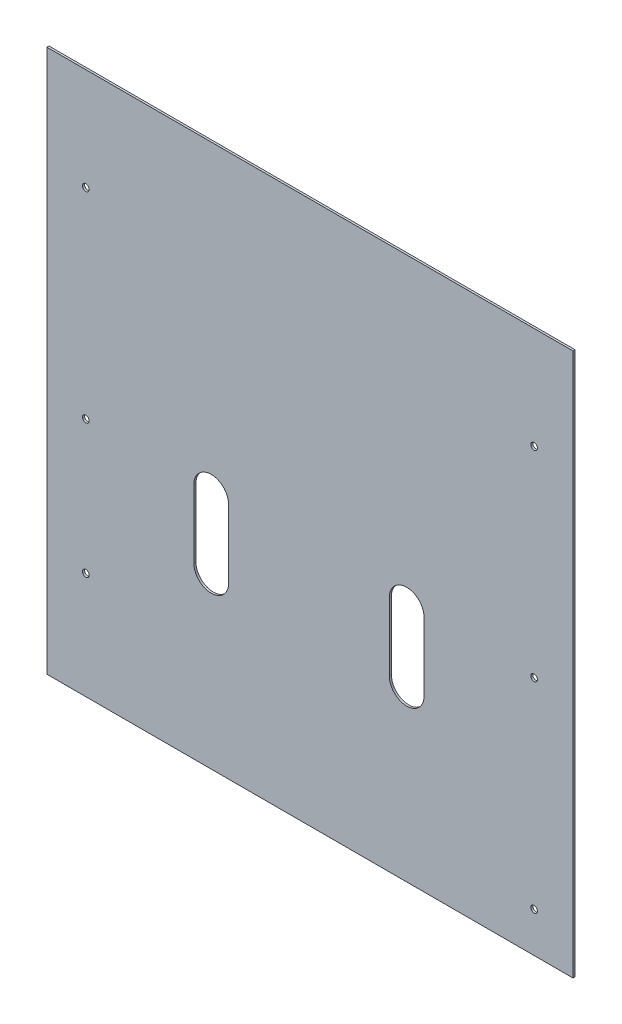
from build123d import *

# Parameters (mm, degrees)
SKETCH1_W                             = 196.85
SKETCH1_H                             = 203.2
BOSS_EXTRUDE1_DEPTH                   = 0.7747
CUT_EXTRUDE7_DEPTH                    = 1.7747
SKETCH4_W                             = 196.85
SKETCH4_H                             = 0.6096
BOSS_EXTRUDE2_DEPTH                   = 12
SKETCH14_W                            = 196.85
SKETCH14_H                            = 11.938
BOSS_EXTRUDE3_DEPTH                   = 0.7747
SKETCH13_W                            = 196.85
SKETCH13_H                            = 0.6096
CUT_EXTRUDE9_DEPTH                    = 12
CSK_FOR_M3_FLAT_HEAD_MACHINE_SCREW3_D = 2.5
SKETCH19_W                            = 182.676330849
SKETCH19_H                            = 33.741187375
BOSS_EXTRUDE4_DEPTH                   = 0.7747
SKETCH21_W                            = 22.718000829
SKETCH21_H                            = 22.312299049
SKETCH21_W_2                          = 21.538835619
SKETCH21_H_2                          = 16.643270878
BOSS_EXTRUDE5_DEPTH                   = 0.7747
SKETCH22_W                            = 13.90531837
SKETCH22_H                            = 14.215216999
SKETCH22_W_2                          = 12.509578485
SKETCH22_H_2                          = 9.075576548
BOSS_EXTRUDE6_DEPTH                   = 0.7747


with BuildPart() as part:
    # Sketch1 → Boss-Extrude1 (new body)
    with BuildSketch(Plane(origin=(0, 0, 0), x_dir=(1, 0, 0), z_dir=(0, 0, -1))):
        with Locations((-104.775, 135.4)):
            Rectangle(SKETCH1_W, SKETCH1_H)
    extrude(amount=BOSS_EXTRUDE1_DEPTH)

    # Sketch2 → Cut-Extrude7 (cut, through all)
    with BuildSketch(Plane(origin=(0, 0, -0.7747), x_dir=(1, 0, 0), z_dir=(0, 0, -1))):
        with BuildLine():
            Line((-135.221253236, 173.5), (-135.221253236, 148))
            ThreePointArc((-135.221253236, 148), (-141.721253236, 141.5), (-148.221253236, 148))
            Line((-148.221253236, 148), (-148.221253236, 173.5))
            ThreePointArc((-148.221253236, 173.5), (-141.721253236, 180), (-135.221253236, 173.5))
        make_face()
        with BuildLine():
            Line((-62.069253236, 173.5), (-62.069253236, 148))
            ThreePointArc((-62.069253236, 148), (-68.569253236, 141.5), (-75.069253236, 148))
            Line((-75.069253236, 148), (-75.069253236, 173.5))
            ThreePointArc((-75.069253236, 173.5), (-68.569253236, 180), (-62.069253236, 173.5))
        make_face()
    extrude(amount=-CUT_EXTRUDE7_DEPTH, mode=Mode.SUBTRACT)

    # Sketch4 → Boss-Extrude2 (add)
    with BuildSketch(Plane.XY):
        with Locations((-104.775, -34.1048)):
            Rectangle(SKETCH4_W, SKETCH4_H)
    extrude(amount=BOSS_EXTRUDE2_DEPTH)

    # Sketch14 → Boss-Extrude3 (add)
    with BuildSketch(Plane.XY):
        with Locations((-104.775, -53.935004147)):
            Rectangle(SKETCH14_W, SKETCH14_H)
    extrude(amount=-BOSS_EXTRUDE3_DEPTH)

    # Sketch13 → Cut-Extrude9 (cut)
    with BuildSketch(Plane.XY.offset(12)):
        with Locations((-104.775, -34.1048)):
            Rectangle(SKETCH13_W, SKETCH13_H)
    extrude(amount=-CUT_EXTRUDE9_DEPTH, mode=Mode.SUBTRACT)

    # CSK for M3 Flat Head Machine Screw3 (through all)
    with Locations(Plane.XY):
        with Locations((-188.645, -72), (-188.645, -222), (-188.645, -197), (-188.645, -172), (-188.645, -147), (-188.645, -122), (-188.645, -97)):
            csk_for_m3_flat_head_machine_screw3 = Hole(CSK_FOR_M3_FLAT_HEAD_MACHINE_SCREW3_D / 2)

    # Mirror1: CSK for M3 Flat Head Machine Screw3 across plane
    add(csk_for_m3_flat_head_machine_screw3.mirror(Plane(origin=(-104.775, 0, 0), x_dir=(0, 0, 1), z_dir=(1, 0, 0))), mode=Mode.SUBTRACT)

    # Sketch19 → Boss-Extrude4 (add)
    with BuildSketch(Plane(origin=(0, 0, -0.7747), x_dir=(-1, 0, 0), z_dir=(0, 0, -1))):
        with Locations((101.266706015, -109.837466763)):
            Rectangle(SKETCH19_W, SKETCH19_H)
    extrude(amount=-BOSS_EXTRUDE4_DEPTH)

    # Sketch21 → Boss-Extrude5 (add)
    with BuildSketch(Plane(origin=(0, 0, -0.7747), x_dir=(-1, 0, 0), z_dir=(0, 0, -1))):
        with Locations((185.571692861, -170.919383368)):
            Rectangle(SKETCH21_W, SKETCH21_H)
        with Locations((24.271371833, -173.753897453)):
            Rectangle(SKETCH21_W_2, SKETCH21_H_2)
    extrude(amount=-BOSS_EXTRUDE5_DEPTH)

    # Sketch22 → Boss-Extrude6 (add)
    with BuildSketch(Plane.XY):
        with Locations((-189.313880795, -220.883843828)):
            Rectangle(SKETCH22_W, SKETCH22_H)
        with Locations((-23.670028487, -197.876391374)):
            Rectangle(SKETCH22_W_2, SKETCH22_H_2)
    extrude(amount=-BOSS_EXTRUDE6_DEPTH)


solid = part.part
